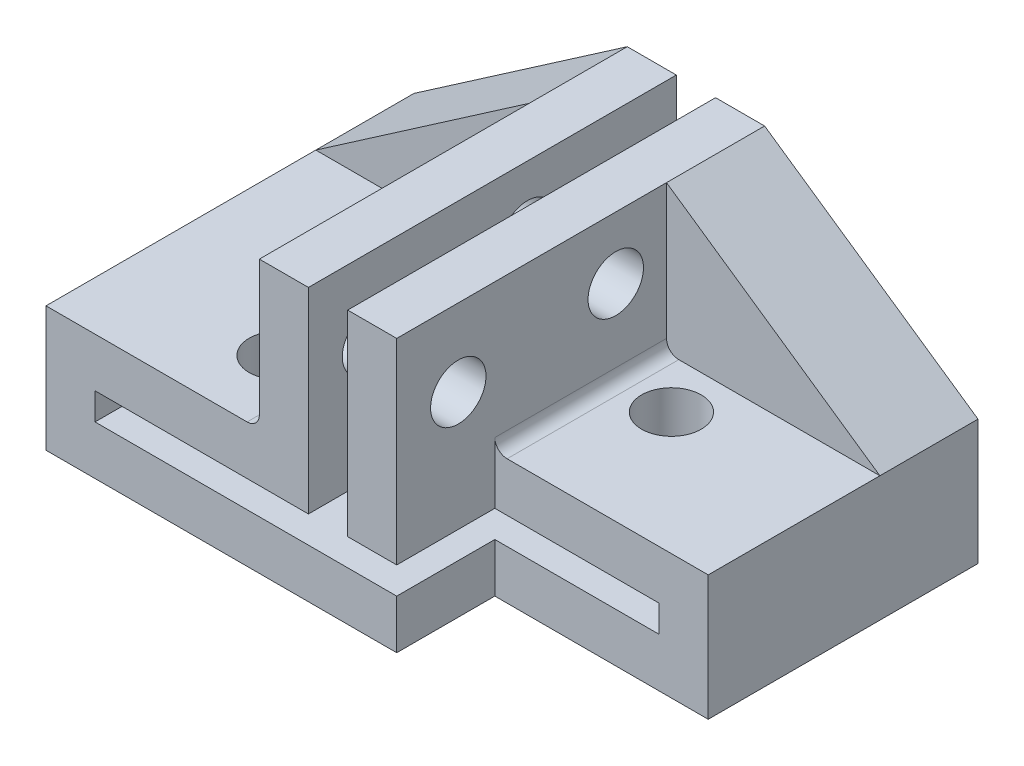
from build123d import *

# Parameters (mm, degrees)
BOSS_EXTRUDE1_DEPTH = 15
SKETCH2_W           = 8.7
SKETCH2_H           = 4
CUT_EXTRUDE1_DEPTH  = 15
SKETCH4_R           = 1.1303
CUT_EXTRUDE2_DEPTH  = 15
SKETCH5_R           = 1.215
CUT_EXTRUDE3_DEPTH  = 15
BOSS_EXTRUDE2_DEPTH = 2
FILLET2_R           = 0.5


with BuildPart() as part:
    # Sketch1 → Boss-Extrude1 (new body)
    with BuildSketch(Plane.XY):
        Polygon((0, 0), (0, -6), (-8.7, -6), (-8.7, -11.1), (14.3, -11.1), (14.3, -6), (5.6, -6), (5.6, 0), (3.6, 0), (3.6, -3.541064843), (3.6, -8), (12.3, -8), (12.3, -9.1), (-6.7, -9.1), (-6.7, -8), (2, -8), (2, 0), align=None)
    extrude(amount=BOSS_EXTRUDE1_DEPTH)

    # Sketch2 → Cut-Extrude1 (cut)
    with BuildSketch(Plane(origin=(0, -6, 0), x_dir=(1, 0, 0), z_dir=(0, 1, 0))):
        with Locations((9.95, -13)):
            Rectangle(SKETCH2_W, SKETCH2_H)
    extrude(amount=-CUT_EXTRUDE1_DEPTH, mode=Mode.SUBTRACT)

    # Sketch4 → Cut-Extrude2 (cut)
    with BuildSketch(Plane.ZY):
        with Locations((12.49, -3.148205104)):
            Circle(SKETCH4_R)
        with Locations((6.069694521, -2.53)):
            Circle(SKETCH4_R)
    extrude(amount=-CUT_EXTRUDE2_DEPTH, mode=Mode.SUBTRACT)

    # Sketch5 → Cut-Extrude3 (cut)
    with BuildSketch(Plane(origin=(0, -6, 0), x_dir=(1, 0, 0), z_dir=(0, 1, 0))):
        with Locations((-2.2, -12)):
            Circle(SKETCH5_R)
        with Locations((7.8, -6)):
            Circle(SKETCH5_R)
        with Locations((-2.2, -6)):
            Circle(SKETCH5_R)
    extrude(amount=-CUT_EXTRUDE3_DEPTH, mode=Mode.SUBTRACT)

    # Sketch6 → Boss-Extrude2 (add, symmetric)
    with BuildSketch(Plane(origin=(0, 0, 2), x_dir=(-1, 0, 0), z_dir=(0, 0, -1))):
        Polygon((0, -6), (8.7, -6), (0, 0), align=None)
    boss_extrude2 = extrude(amount=BOSS_EXTRUDE2_DEPTH, both=True)

    # Mirror1: Boss-Extrude2 across plane
    add(boss_extrude2.mirror(Plane(origin=(2.8, 0, 0), x_dir=(0, 0, 1), z_dir=(1, 0, 0))))

    # Fillet2
    fillet2_edges = [part.edges().sort_by_distance(p)[0] for p in [
        (0, -6, 9.5),
        (5.6, -6, 7.5),
    ]]
    fillet(fillet2_edges, radius=FILLET2_R)


solid = part.part
